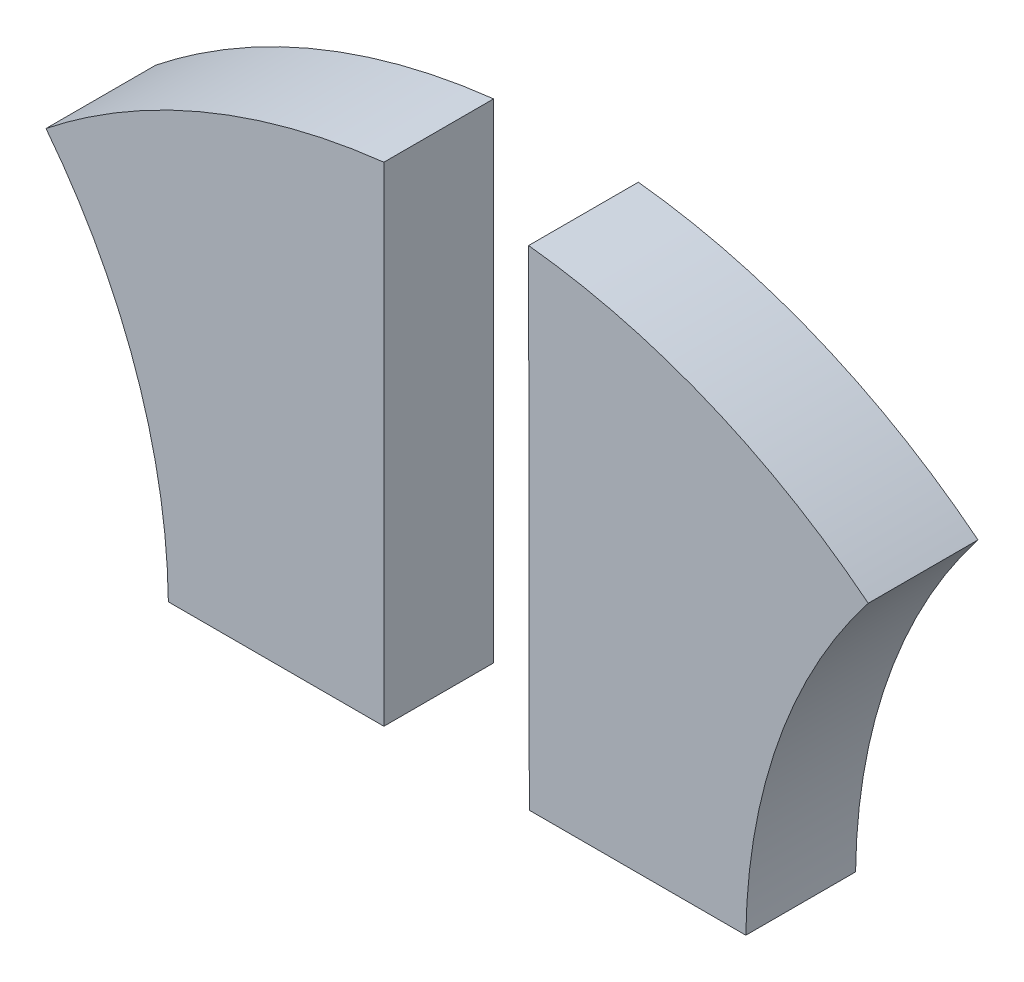
from build123d import *

# Parameters (mm, degrees)
SALIENTE_EXTRUIR1_DEPTH   = 3
SALIENTE_EXTRUIR1_2_DEPTH = 3


with BuildPart() as part:
    # Model → Saliente-Extruir1 (new body)
    with BuildSketch(Plane.XY):
        with BuildLine():
            Line((28.504746215, 11.01914405), (34.397149805, 11.01914405))
            Line((34.397149805, 11.01914405), (34.397149805, 24.375550539))
            add(Edge.make_bspline(
                [(34.397149805, 24.375550539), (29.241616022, 23.797846573), (25.15911927, 20.554975457)],
                knots=[3.251706493, 3.251706493, 3.251706493, 3.806338024, 3.806338024, 3.806338024], degree=2, weights=[1, 0.961769503, 0.999950817]))
            ThreePointArc((25.15911927, 20.554975457), (27.614337529, 16.061564872), (28.504746215, 11.01914405))
        make_face()
    extrude(amount=SALIENTE_EXTRUIR1_DEPTH)


with BuildPart() as body_2:
    # Model → Saliente-Extruir1 2 (new body)
    with BuildSketch(Plane.XY):
        with BuildLine():
            Line((38.372926733, 11.01914405), (44.29332666, 11.01914405))
            ThreePointArc((44.29332666, 11.01914405), (45.184353453, 16.061545628), (47.640831503, 20.554368572))
            add(Edge.make_bspline(
                [(47.640831503, 20.554368572), (43.537574655, 23.814087787), (38.35411017, 24.38085595)],
                knots=[2.476794104, 2.476794104, 2.476794104, 3.034124618, 3.034124618, 3.034124618], degree=2, weights=[0.999950091, 0.961398815, 1]))
            Line((38.35411017, 24.38085595), (38.372926733, 11.01914405))
        make_face()
    extrude(amount=SALIENTE_EXTRUIR1_2_DEPTH)


solid = Compound([part.part, body_2.part])
